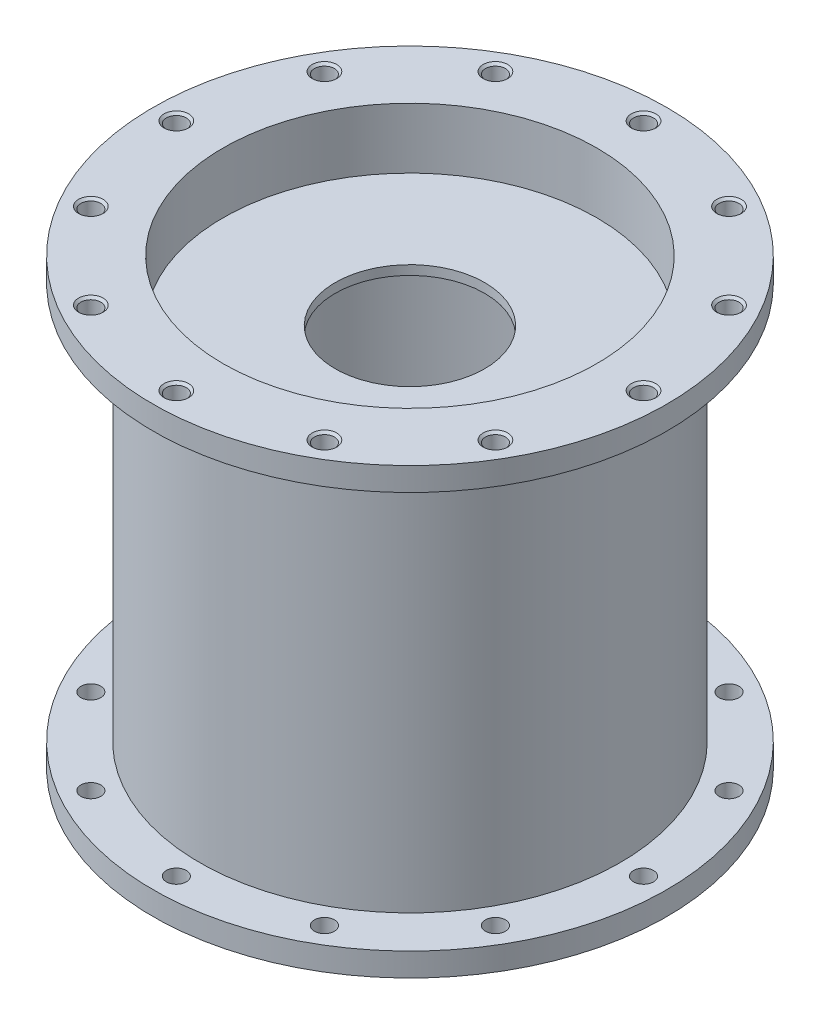
from build123d import *

# Parameters (mm, degrees)
SKETCH4_W                            = 30.48
SKETCH4_H                            = 2.54
F_3_0_213_DIAMETER_HOLE1_AT_2_COUNT  = 2
F_3_0_213_DIAMETER_HOLE1_AT_2_PITCH  = 63.5
F_3_0_213_DIAMETER_HOLE1_AT_3_COUNT  = 2
F_3_0_213_DIAMETER_HOLE1_AT_3_PITCH  = 32.870018728
F_3_0_213_DIAMETER_HOLE1_AT_4_COUNT  = 2
F_3_0_213_DIAMETER_HOLE1_AT_4_PITCH  = 63.5
F_3_0_213_DIAMETER_HOLE1_AT_5_COUNT  = 2
F_3_0_213_DIAMETER_HOLE1_AT_5_PITCH  = 89.802561211
F_3_0_213_DIAMETER_HOLE1_AT_6_COUNT  = 2
F_3_0_213_DIAMETER_HOLE1_AT_6_PITCH  = 109.985226281
F_3_0_213_DIAMETER_HOLE1_AT_7_COUNT  = 2
F_3_0_213_DIAMETER_HOLE1_AT_7_PITCH  = 122.672579939
F_3_0_213_DIAMETER_HOLE1_AT_8_COUNT  = 2
F_3_0_213_DIAMETER_HOLE1_AT_8_PITCH  = 127
F_3_0_213_DIAMETER_HOLE1_AT_9_COUNT  = 2
F_3_0_213_DIAMETER_HOLE1_AT_9_PITCH  = 122.672579939
F_3_0_213_DIAMETER_HOLE1_AT_10_COUNT = 2
F_3_0_213_DIAMETER_HOLE1_AT_10_PITCH = 109.985226281
F_3_0_213_DIAMETER_HOLE1_AT_11_COUNT = 2
F_3_0_213_DIAMETER_HOLE1_AT_11_PITCH = 89.802561211
F_3_0_213_DIAMETER_HOLE1_AT_12_COUNT = 2
F_3_0_213_DIAMETER_HOLE1_AT_12_PITCH = 63.5
F_3_0_213_DIAMETER_HOLE1_AT_13_COUNT = 2
F_3_0_213_DIAMETER_HOLE1_AT_13_PITCH = 32.870018728


with BuildPart() as part:
    # Sketch1 → Chamber (revolve)
    with BuildSketch(Plane(origin=(0, 0, 0), x_dir=(0, 0, -1), z_dir=(1, 0, 0))):
        Polygon((57.15, 6.35), (57.15, 114.3), (69.85, 114.3), (69.85, 120.65), (57.15, 120.65), (50.8, 120.65), (50.8, 114.3), (50.8, 6.35), (50.8, 0), (57.15, 0), (69.85, 0), (69.85, 6.35), align=None)
    revolve(axis=Axis((0, 0, 0), (0, 1, 0)))

    # Sketch4 → Turbulence Rings (revolve)
    with BuildSketch(Plane(origin=(0, 0, 0), x_dir=(0, 0, -1), z_dir=(1, 0, 0))):
        with Locations((35.56, 102.931657822)):
            Rectangle(SKETCH4_W, SKETCH4_H)
        with Locations((35.56, 17.718342178)):
            Rectangle(SKETCH4_W, SKETCH4_H)
    revolve(axis=Axis((0, 0, 0), (0, 1, 0)))

    # Sketch6 → #3 (0.213) Diameter Hole1 (revolve, cut)
    with BuildSketch(Plane(origin=(-54.99261314, 120.65, 31.75), x_dir=(0, 0, 1), z_dir=(1, 0, 0))):
        Polygon((0, 0), (0, 120.65), (3.3401, 120.65), (2.7051, 120.015), (2.7051, 0.635), (3.3401, 0), align=None)
    f_3_0_213_diameter_hole1 = revolve(axis=Axis((-54.99261314, 127, 31.75), (0, -1, 0)), mode=Mode.SUBTRACT)

    # #3 (0.213) Diameter Hole1 at 2: #3 (0.213) Diameter Hole1 ×2
    with Locations(*[Vector(0.866025404, 0, -0.5) * (i * F_3_0_213_DIAMETER_HOLE1_AT_2_PITCH) for i in range(1, F_3_0_213_DIAMETER_HOLE1_AT_2_COUNT)]):
        add(f_3_0_213_diameter_hole1, mode=Mode.SUBTRACT)

    # #3 (0.213) Diameter Hole1 at 3: #3 (0.213) Diameter Hole1 ×2
    with Locations(*[Vector(-0.258819045, 0, -0.965925826) * (i * F_3_0_213_DIAMETER_HOLE1_AT_3_PITCH) for i in range(1, F_3_0_213_DIAMETER_HOLE1_AT_3_COUNT)]):
        add(f_3_0_213_diameter_hole1, mode=Mode.SUBTRACT)

    # #3 (0.213) Diameter Hole1 at 4: #3 (0.213) Diameter Hole1 ×2
    with Locations(*[(0, 0, -i * F_3_0_213_DIAMETER_HOLE1_AT_4_PITCH) for i in range(1, F_3_0_213_DIAMETER_HOLE1_AT_4_COUNT)]):
        add(f_3_0_213_diameter_hole1, mode=Mode.SUBTRACT)

    # #3 (0.213) Diameter Hole1 at 5: #3 (0.213) Diameter Hole1 ×2
    with Locations(*[Vector(0.258819045, 0, -0.965925826) * (i * F_3_0_213_DIAMETER_HOLE1_AT_5_PITCH) for i in range(1, F_3_0_213_DIAMETER_HOLE1_AT_5_COUNT)]):
        add(f_3_0_213_diameter_hole1, mode=Mode.SUBTRACT)

    # #3 (0.213) Diameter Hole1 at 6: #3 (0.213) Diameter Hole1 ×2
    with Locations(*[Vector(0.5, 0, -0.866025404) * (i * F_3_0_213_DIAMETER_HOLE1_AT_6_PITCH) for i in range(1, F_3_0_213_DIAMETER_HOLE1_AT_6_COUNT)]):
        add(f_3_0_213_diameter_hole1, mode=Mode.SUBTRACT)

    # #3 (0.213) Diameter Hole1 at 7: #3 (0.213) Diameter Hole1 ×2
    with Locations(*[Vector(0.707106781, 0, -0.707106781) * (i * F_3_0_213_DIAMETER_HOLE1_AT_7_PITCH) for i in range(1, F_3_0_213_DIAMETER_HOLE1_AT_7_COUNT)]):
        add(f_3_0_213_diameter_hole1, mode=Mode.SUBTRACT)

    # #3 (0.213) Diameter Hole1 at 8: #3 (0.213) Diameter Hole1 ×2
    with Locations(*[Vector(0.866025404, 0, -0.5) * (i * F_3_0_213_DIAMETER_HOLE1_AT_8_PITCH) for i in range(1, F_3_0_213_DIAMETER_HOLE1_AT_8_COUNT)]):
        add(f_3_0_213_diameter_hole1, mode=Mode.SUBTRACT)

    # #3 (0.213) Diameter Hole1 at 9: #3 (0.213) Diameter Hole1 ×2
    with Locations(*[Vector(0.965925826, 0, -0.258819045) * (i * F_3_0_213_DIAMETER_HOLE1_AT_9_PITCH) for i in range(1, F_3_0_213_DIAMETER_HOLE1_AT_9_COUNT)]):
        add(f_3_0_213_diameter_hole1, mode=Mode.SUBTRACT)

    # #3 (0.213) Diameter Hole1 at 10: #3 (0.213) Diameter Hole1 ×2
    with Locations(*[(i * F_3_0_213_DIAMETER_HOLE1_AT_10_PITCH, 0, 0) for i in range(1, F_3_0_213_DIAMETER_HOLE1_AT_10_COUNT)]):
        add(f_3_0_213_diameter_hole1, mode=Mode.SUBTRACT)

    # #3 (0.213) Diameter Hole1 at 11: #3 (0.213) Diameter Hole1 ×2
    with Locations(*[Vector(0.965925826, 0, 0.258819045) * (i * F_3_0_213_DIAMETER_HOLE1_AT_11_PITCH) for i in range(1, F_3_0_213_DIAMETER_HOLE1_AT_11_COUNT)]):
        add(f_3_0_213_diameter_hole1, mode=Mode.SUBTRACT)

    # #3 (0.213) Diameter Hole1 at 12: #3 (0.213) Diameter Hole1 ×2
    with Locations(*[Vector(0.866025404, 0, 0.5) * (i * F_3_0_213_DIAMETER_HOLE1_AT_12_PITCH) for i in range(1, F_3_0_213_DIAMETER_HOLE1_AT_12_COUNT)]):
        add(f_3_0_213_diameter_hole1, mode=Mode.SUBTRACT)

    # #3 (0.213) Diameter Hole1 at 13: #3 (0.213) Diameter Hole1 ×2
    with Locations(*[Vector(0.707106781, 0, 0.707106781) * (i * F_3_0_213_DIAMETER_HOLE1_AT_13_PITCH) for i in range(1, F_3_0_213_DIAMETER_HOLE1_AT_13_COUNT)]):
        add(f_3_0_213_diameter_hole1, mode=Mode.SUBTRACT)


solid = part.part
